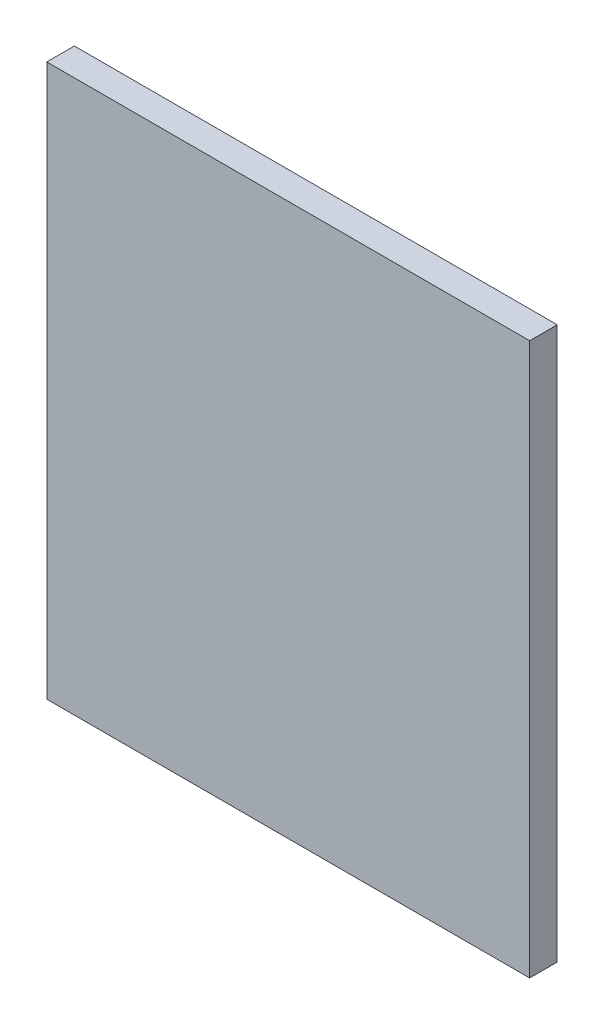
from build123d import *

# Parameters (mm, degrees)
SKETCH1_W           = 350
SKETCH1_H           = 400
BOSS_EXTRUDE1_DEPTH = 20


with BuildPart() as part:
    # Sketch1 → Boss-Extrude1 (new body)
    with BuildSketch(Plane.XY):
        Rectangle(SKETCH1_W, SKETCH1_H)
    extrude(amount=BOSS_EXTRUDE1_DEPTH)


solid = part.part
